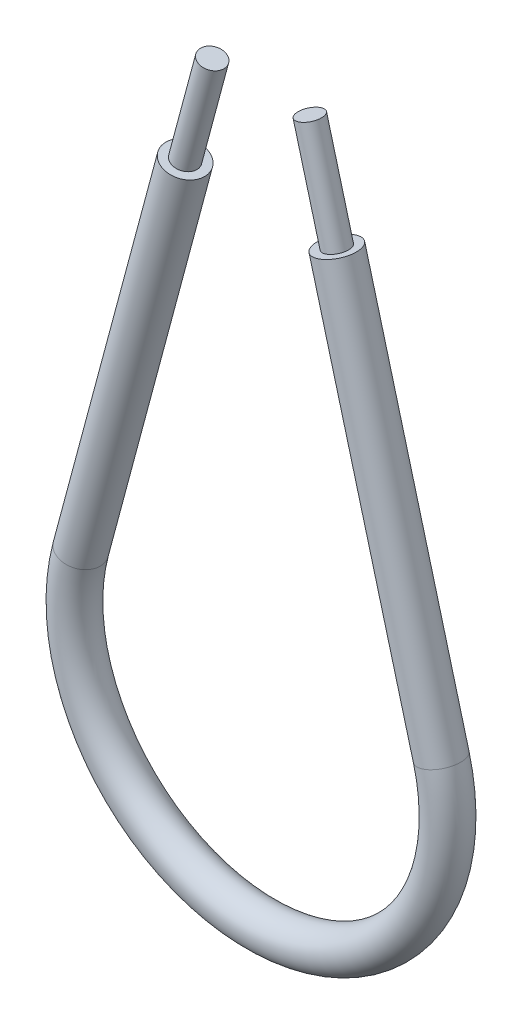
from build123d import *

# Parameters (mm, degrees)
SKETCH3_R   = 2.38125
SKETCH4_R   = 3.96875
SKETCH4_R_2 = 2.38125


with BuildPart() as part:
    # Sweep1: sweep along a path in Sketch2
    with BuildLine(Plane.XY) as sweep1_path:
        Line((-114.365151202, 4.504376727), (-88.389976761, -92.436294023))
        ThreePointArc((-88.389976761, -92.436294023), (-124.004465969, -138.85), (-159.618955177, -92.436294023))
        Line((-159.618955177, -92.436294023), (-133.643780736, 4.504376727))
    # Sketch3 → Sweep1 (sweep)
    with BuildSketch(Plane(origin=(-114.365151202, 4.504376727, 0), x_dir=(-0.965925826, -0.258819045, 0), z_dir=(0.258819045, -0.965925826, 0))):
        Circle(SKETCH3_R)
    sweep(path=sweep1_path.line)


with BuildPart() as body_2:
    # Sweep2: sweep along a path in Sketch5
    with BuildLine(Plane.XY) as sweep2_path:
        Line((-138.985158779, -15.429917513), (-159.618955177, -92.436294023))
        ThreePointArc((-159.618955177, -92.436294023), (-124.004465969, -138.85), (-88.389976761, -92.436294023))
        Line((-88.389976761, -92.436294023), (-109.023773159, -15.429917513))
    # Sketch4 → Sweep2 (sweep)
    with BuildSketch(Plane(origin=(-3.445728615, 12.859634261, 0), x_dir=(0.965925826, 0.258819045, 0), z_dir=(0.258819045, -0.965925826, 0))):
        with Locations((-109.302434691, 0)):
            Circle(SKETCH4_R)
        with Locations((-109.302434691, 0)):
            Circle(SKETCH4_R_2, mode=Mode.SUBTRACT)
    sweep(path=sweep2_path.line)


solid = Compound([part.part, body_2.part])
